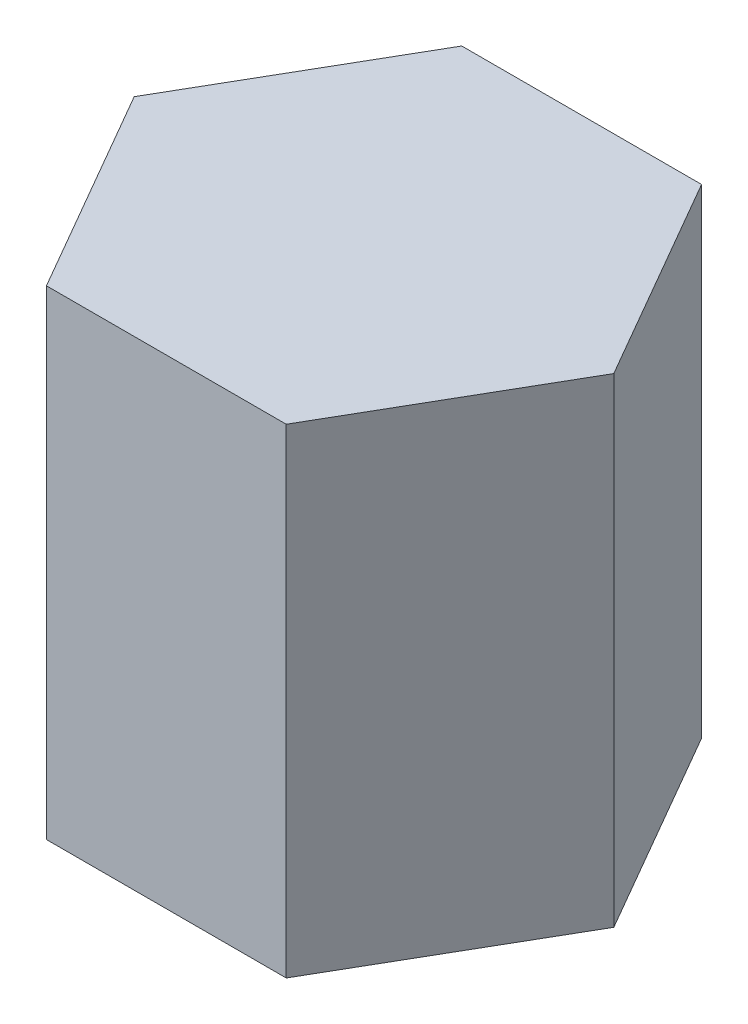
from build123d import *

# Parameters (mm, degrees)
BOSS_EXTRUDE1_DEPTH = 50.8


with BuildPart() as part:
    # Sketch1 → Boss-Extrude1 (new body)
    with BuildSketch(Plane(origin=(0, 0, 0), x_dir=(1, 0, 0), z_dir=(0, 1, 0))):
        Polygon((0, 0), (-25.4, 0), (-38.1, 21.997045256), (-25.4, 43.994090512), (0, 43.994090512), (12.7, 21.997045256), align=None)
    extrude(amount=BOSS_EXTRUDE1_DEPTH)


solid = part.part
